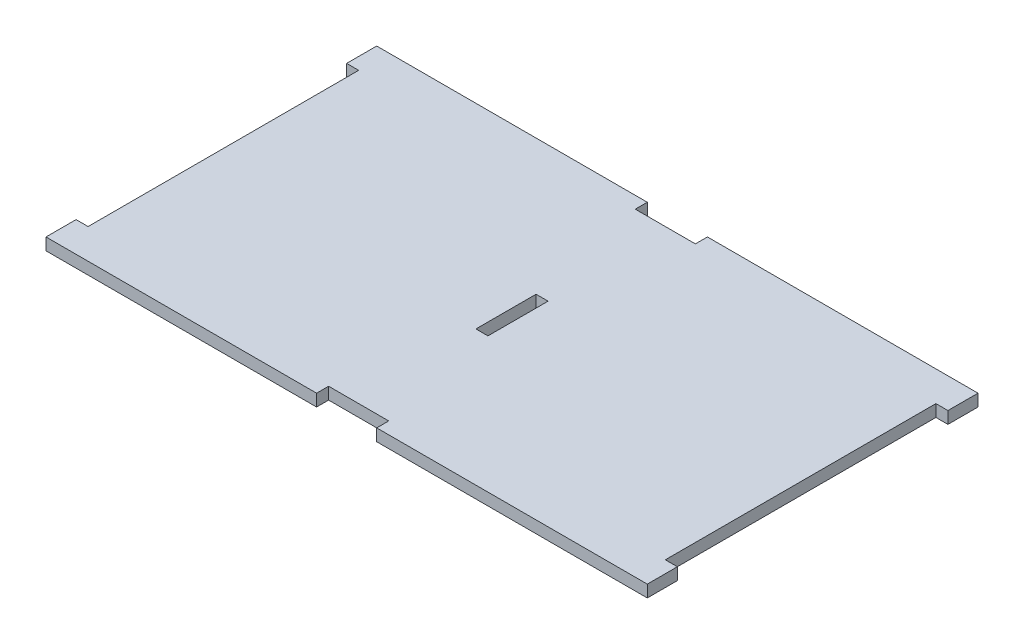
from build123d import *

# Parameters (mm, degrees)
SKETCH1_W           = 2
SKETCH1_H           = 10
BOSS_EXTRUDE1_DEPTH = 2


with BuildPart() as part:
    # Sketch1 → Boss-Extrude1 (new body)
    with BuildSketch(Plane(origin=(0, 0, 0), x_dir=(1, 0, 0), z_dir=(0, 1, 0))):
        Polygon((-50, 22.5), (-48, 22.5), (-48, -22.5), (-50, -22.5), (-50, -27.5), (-5, -27.5), (-5, -25.5), (5, -25.5), (5, -27.5), (50, -27.5), (50, -22.5), (48, -22.5), (48, 22.5), (50, 22.5), (50, 27.5), (5, 27.5), (5, 25.5), (-5, 25.5), (-5, 27.5), (-50, 27.5), align=None)
        Rectangle(SKETCH1_W, SKETCH1_H, mode=Mode.SUBTRACT)
    extrude(amount=BOSS_EXTRUDE1_DEPTH)


solid = part.part
